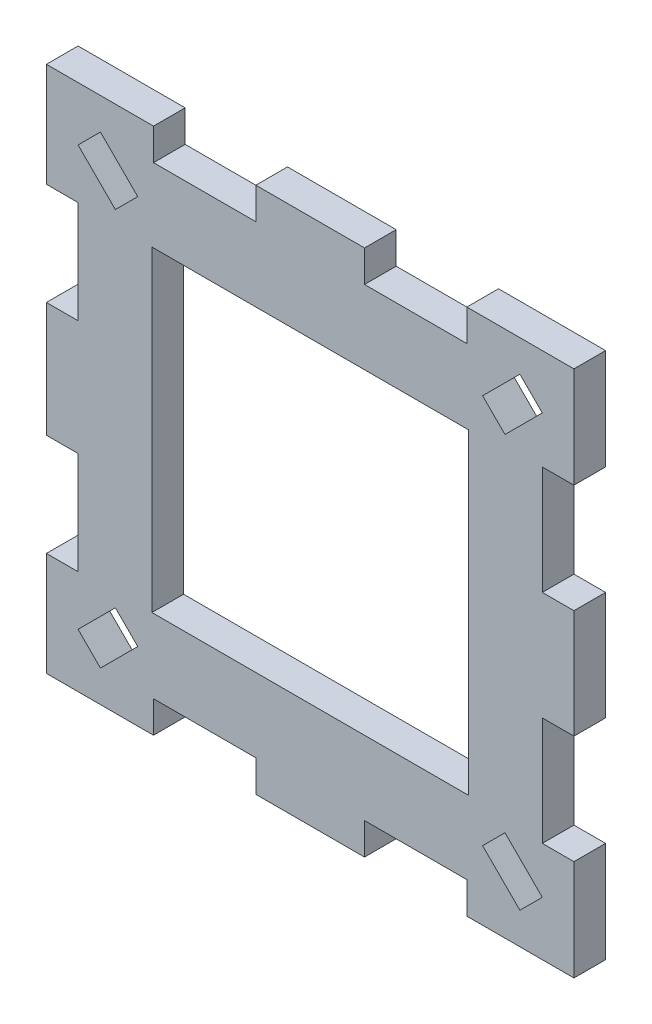
from build123d import *

# Parameters (mm, degrees)
SALIENTE_EXTRUIR1_DEPTH = 3
CROQUIS2_W              = 30
CROQUIS2_H              = 30
CORTAR_EXTRUIR2_DEPTH   = 3
CORTAR_EXTRUIR3_DEPTH   = 3


with BuildPart() as part:
    # Croquis1 → Saliente-Extruir1 (new body)
    with BuildSketch(Plane.XY):
        Polygon((-25, -25), (-14.85, -25), (-14.85, -22), (-5.15, -22), (-5.15, -25), (5.15, -25), (5.15, -22), (14.85, -22), (14.85, -25), (25, -25), (25, -15.45), (22, -15.45), (22, -5.15), (25, -5.15), (25, 5.15), (22, 5.15), (22, 15.45), (25, 15.45), (25, 25), (14.85, 25), (14.85, 22), (5.15, 22), (5.15, 25), (-5.15, 25), (-5.15, 22), (-14.85, 22), (-14.85, 25), (-25, 25), (-25, 15.15), (-22, 15.15), (-22, 5.45), (-25, 5.45), (-25, -5.45), (-22, -5.45), (-22, -15.15), (-25, -15.15), align=None)
    extrude(amount=SALIENTE_EXTRUIR1_DEPTH)

    # Croquis2 → Cortar-Extruir2 (cut)
    with BuildSketch(Plane.XY.offset(3)):
        Rectangle(CROQUIS2_W, CROQUIS2_H)
    extrude(amount=-CORTAR_EXTRUIR2_DEPTH, mode=Mode.SUBTRACT)

    # Croquis3 → Cortar-Extruir3 (cut)
    with BuildSketch(Plane.XY.offset(3)):
        Polygon((-19.878679656, -22), (-16.343145751, -18.464466094), (-18.464466094, -16.343145751), (-22, -19.878679656), align=None)
        Polygon((16.343145751, -18.464466094), (18.464466094, -16.343145751), (22, -19.878679656), (19.878679656, -22), align=None)
        Polygon((22, 19.878679656), (18.464466094, 16.343145751), (16.343145751, 18.464466094), (19.878679656, 22), align=None)
        Polygon((-22, 19.878679656), (-18.464466094, 16.343145751), (-16.343145751, 18.464466094), (-19.878679656, 22), align=None)
    extrude(amount=-CORTAR_EXTRUIR3_DEPTH, mode=Mode.SUBTRACT)


solid = part.part
